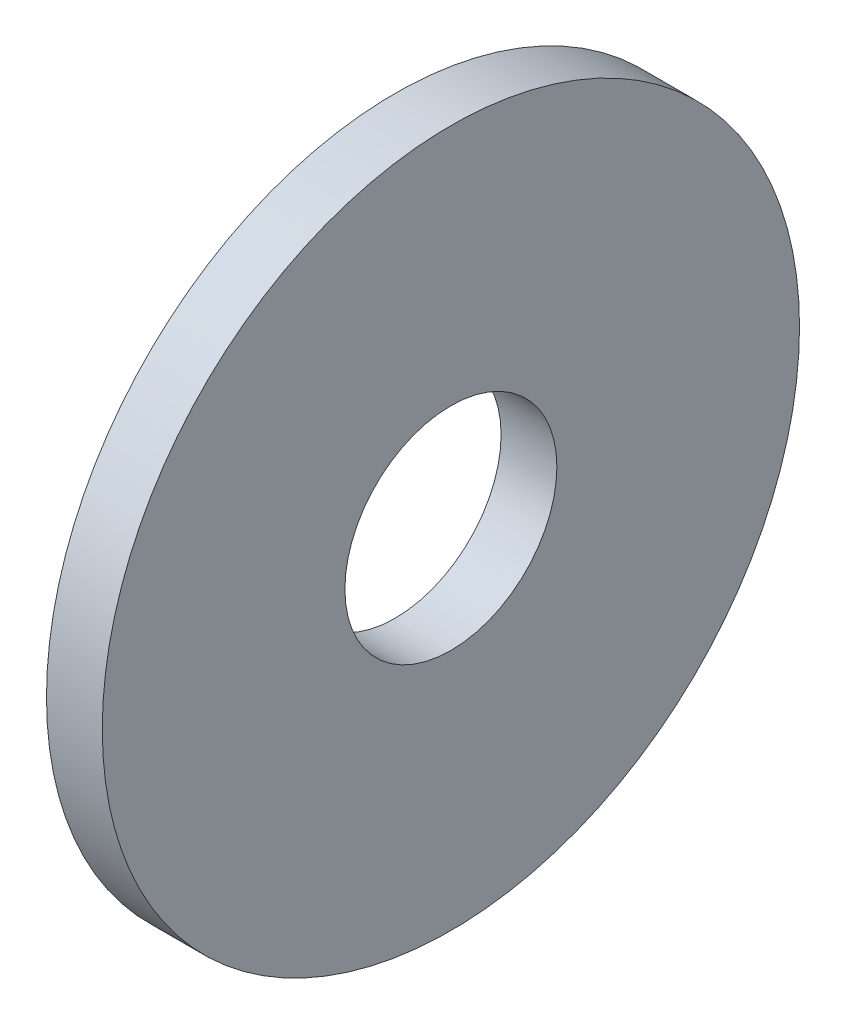
from build123d import *

# Parameters (mm, degrees)
SKETCH1_W = 1.778
SKETCH1_H = 7.7343


with BuildPart() as part:
    # Sketch1 → Revolve1 (revolve)
    with BuildSketch(Plane(origin=(0, 0, 0), x_dir=(-1, 0, 0), z_dir=(0, 0, -1))):
        with Locations((-0.889, 7.24535)):
            Rectangle(SKETCH1_W, SKETCH1_H)
    revolve(axis=Axis((1.778, 0, 0), (-1, 0, 0)))


solid = part.part
